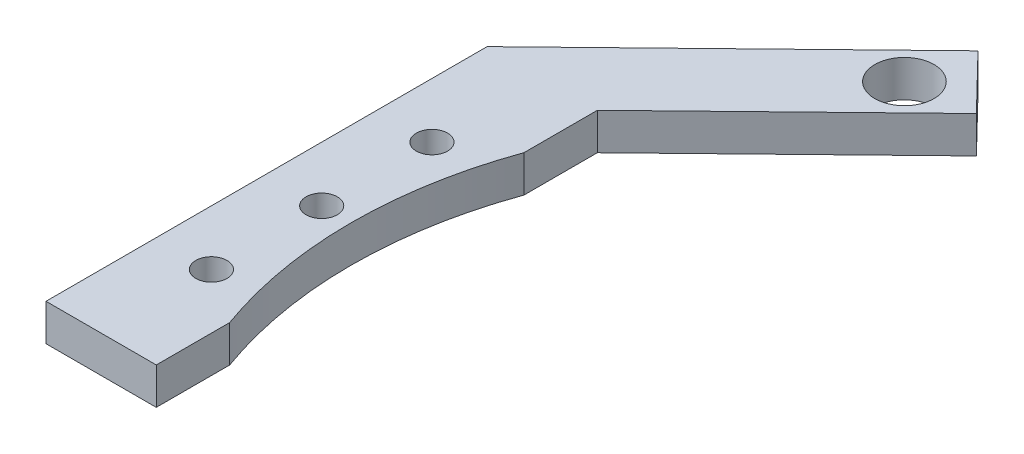
from build123d import *

# Parameters (mm, degrees)
SKETCH1_R               = 4.025
SKETCH1_R_2             = 2.125
BOSS_EXTRUDE1_DEPTH     = 2.5
SKETCH2_R               = 59
CUT_EXTRUDE1_DEPTH      = 3.5
CUT_EXTRUDE1_DEPTH_BACK = 3.5


with BuildPart() as part:
    # Sketch1 → Boss-Extrude1 (new body, symmetric)
    with BuildSketch(Plane(origin=(0, 0, 0), x_dir=(1, 0, 0), z_dir=(0, 1, 0))):
        Polygon((-55.5, 30), (-55.5, -30), (-70.5, -30), (-70.5, 30), (-36.615368979, 62.892866181), (-29.338096583, 55.396174082), align=None)
        with Locations((-37.999438908, 54.268822934)):
            Circle(SKETCH1_R, mode=Mode.SUBTRACT)
        with Locations((-63, 0)):
            Circle(SKETCH1_R_2, mode=Mode.SUBTRACT)
        with Locations((-63, -15)):
            Circle(SKETCH1_R_2, mode=Mode.SUBTRACT)
        with Locations((-63, 15)):
            Circle(SKETCH1_R_2, mode=Mode.SUBTRACT)
    extrude(amount=BOSS_EXTRUDE1_DEPTH, both=True)

    # Sketch2 → Cut-Extrude1 (cut, two sides)
    with BuildSketch(Plane(origin=(0, 0, 0), x_dir=(1, 0, 0), z_dir=(0, 1, 0))) as cut_extrude1_sk:
        Circle(SKETCH2_R)
    extrude(amount=CUT_EXTRUDE1_DEPTH, mode=Mode.SUBTRACT)
    extrude(cut_extrude1_sk.sketch, amount=-CUT_EXTRUDE1_DEPTH_BACK, mode=Mode.SUBTRACT)


solid = part.part
